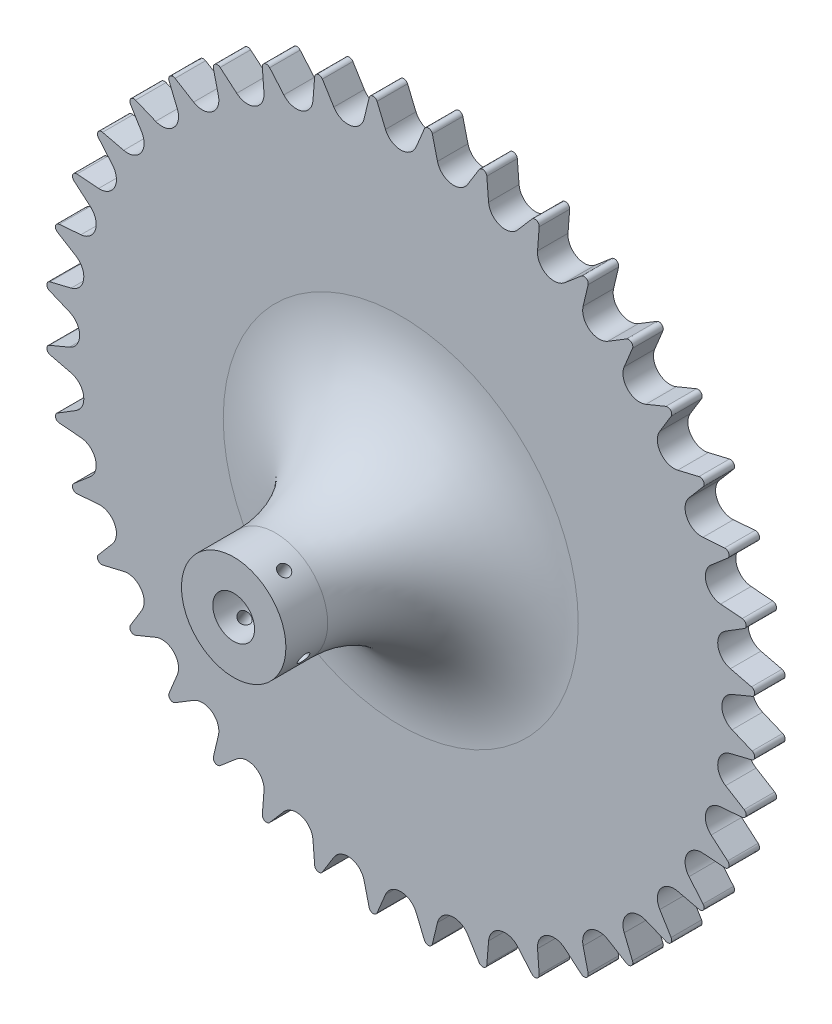
from build123d import *

# Parameters (mm, degrees)
BOSS_EXTRUDE1_DEPTH                 = 7.3
SKETCH2_R                           = 12.5
BOSS_EXTRUDE2_DEPTH                 = 40
FILLET1_R                           = 30
SKETCH3_R                           = 5
CUT_EXTRUDE1_DEPTH                  = 48.3
F_1_0MM_DOWEL_HOLE1_D               = 2.8
F_1_0MM_DOWEL_HOLE1_DEPTH           = 33.158795133
F_1_0MM_DOWEL_HOLE1_TIP             = 0.841204867
F_1_0MM_DOWEL_HOLE1_ON_FACE_2_D     = 2.8
F_1_0MM_DOWEL_HOLE1_ON_FACE_2_DEPTH = 33.158795133
F_1_0MM_DOWEL_HOLE1_ON_FACE_2_TIP   = 0.841204867


with BuildPart() as part:
    # Sketch1 → Boss-Extrude1 (new body)
    with BuildSketch(Plane.XY):
        with BuildLine():
            ThreePointArc((3.662609618, 79.321514688), (0, 76.88125), (-3.662609618, 79.321514688))
            Line((-3.662609618, 79.321514688), (-5.667701775, 84.126186191))
            ThreePointArc((-5.667701775, 84.126186191), (-6.669023137, 84.737973367), (-7.562311971, 83.977077135))
            Line((-7.562311971, 83.977077135), (-8.791101901, 78.917893592))
            ThreePointArc((-8.791101901, 78.917893592), (-12.026877215, 75.934714235), (-16.026135532, 77.77197684))
            Line((-16.026135532, 77.77197684), (-18.758157894, 82.203829344))
            ThreePointArc((-18.758157894, 82.203829344), (-19.842855928, 82.651443234), (-20.606116499, 81.760173735))
            Line((-20.606116499, 81.760173735), (-21.028347314, 76.571052042))
            ThreePointArc((-21.028347314, 76.571052042), (-23.757612799, 73.118413793), (-27.995044802, 74.307434811))
            Line((-27.995044802, 74.307434811), (-31.386725911, 78.2573414))
            ThreePointArc((-31.386725911, 78.2573414), (-32.528091751, 78.529760263), (-33.142530051, 77.530063512))
            Line((-33.142530051, 77.530063512), (-32.747805028, 72.338777067))
            ThreePointArc((-32.747805028, 72.338777067), (-34.903357108, 68.501695338), (-39.274623159, 69.013197125))
            Line((-39.274623159, 69.013197125), (-43.242448569, 72.38389799))
            ThreePointArc((-43.242448569, 72.38389799), (-44.412378001, 72.47441397), (-44.862864519, 71.390905818))
            Line((-44.862864519, 71.390905818), (-43.660903098, 66.325281321))
            ThreePointArc((-43.660903098, 66.325281321), (-45.189664928, 62.198237799), (-49.587129948, 62.019625484))
            Line((-49.587129948, 62.019625484), (-54.03339863, 64.728122783))
            ThreePointArc((-54.03339863, 64.728122783), (-55.203084108, 64.634507076), (-55.478526372, 63.49386709))
            Line((-55.478526372, 63.49386709), (-53.498924832, 58.678637028))
            ThreePointArc((-53.498924832, 58.678637028), (-54.363253221, 54.363253221), (-58.678637028, 53.498924832))
            Line((-58.678637028, 53.498924832), (-63.49386709, 55.478526372))
            ThreePointArc((-63.49386709, 55.478526372), (-64.634507076, 55.203084108), (-64.728122783, 54.03339863))
            Line((-64.728122783, 54.03339863), (-62.019625484, 49.587129948))
            ThreePointArc((-62.019625484, 49.587129948), (-62.198237799, 45.189664928), (-66.325281321, 43.660903098))
            Line((-66.325281321, 43.660903098), (-71.390905818, 44.862864519))
            ThreePointArc((-71.390905818, 44.862864519), (-72.47441397, 44.412378001), (-72.38389799, 43.242448569))
            Line((-72.38389799, 43.242448569), (-69.013197125, 39.274623159))
            ThreePointArc((-69.013197125, 39.274623159), (-68.501695338, 34.903357108), (-72.338777067, 32.747805028))
            Line((-72.338777067, 32.747805028), (-77.530063512, 33.142530051))
            ThreePointArc((-77.530063512, 33.142530051), (-78.529760263, 32.528091751), (-78.2573414, 31.386725911))
            Line((-78.2573414, 31.386725911), (-74.307434811, 27.995044802))
            ThreePointArc((-74.307434811, 27.995044802), (-73.118413793, 23.757612799), (-76.571052042, 21.028347314))
            Line((-76.571052042, 21.028347314), (-81.760173735, 20.606116499))
            ThreePointArc((-81.760173735, 20.606116499), (-82.651443234, 19.842855928), (-82.203829344, 18.758157894))
            Line((-82.203829344, 18.758157894), (-77.77197684, 16.026135532))
            ThreePointArc((-77.77197684, 16.026135532), (-75.934714235, 12.026877215), (-78.917893592, 8.791101901))
            Line((-78.917893592, 8.791101901), (-83.977077135, 7.562311971))
            ThreePointArc((-83.977077135, 7.562311971), (-84.737973367, 6.669023137), (-84.126186191, 5.667701775))
            Line((-84.126186191, 5.667701775), (-79.321514688, 3.662609618))
            ThreePointArc((-79.321514688, 3.662609618), (-76.88125, 0), (-79.321514688, -3.662609618))
            Line((-79.321514688, -3.662609618), (-84.126186191, -5.667701775))
            ThreePointArc((-84.126186191, -5.667701775), (-84.737973367, -6.669023137), (-83.977077135, -7.562311971))
            Line((-83.977077135, -7.562311971), (-78.917893592, -8.791101901))
            ThreePointArc((-78.917893592, -8.791101901), (-75.934714235, -12.026877215), (-77.77197684, -16.026135532))
            Line((-77.77197684, -16.026135532), (-82.203829344, -18.758157894))
            ThreePointArc((-82.203829344, -18.758157894), (-82.651443234, -19.842855928), (-81.760173735, -20.606116499))
            Line((-81.760173735, -20.606116499), (-76.571052042, -21.028347314))
            ThreePointArc((-76.571052042, -21.028347314), (-73.118413793, -23.757612799), (-74.307434811, -27.995044802))
            Line((-74.307434811, -27.995044802), (-78.2573414, -31.386725911))
            ThreePointArc((-78.2573414, -31.386725911), (-78.529760263, -32.528091751), (-77.530063512, -33.142530051))
            Line((-77.530063512, -33.142530051), (-72.338777067, -32.747805028))
            ThreePointArc((-72.338777067, -32.747805028), (-68.501695338, -34.903357108), (-69.013197125, -39.274623159))
            Line((-69.013197125, -39.274623159), (-72.38389799, -43.242448569))
            ThreePointArc((-72.38389799, -43.242448569), (-72.47441397, -44.412378001), (-71.390905818, -44.862864519))
            Line((-71.390905818, -44.862864519), (-66.325281321, -43.660903098))
            ThreePointArc((-66.325281321, -43.660903098), (-62.198237799, -45.189664928), (-62.019625484, -49.587129948))
            Line((-62.019625484, -49.587129948), (-64.728122783, -54.03339863))
            ThreePointArc((-64.728122783, -54.03339863), (-64.634507076, -55.203084108), (-63.49386709, -55.478526372))
            Line((-63.49386709, -55.478526372), (-58.678637028, -53.498924832))
            ThreePointArc((-58.678637028, -53.498924832), (-54.363253221, -54.363253221), (-53.498924832, -58.678637028))
            Line((-53.498924832, -58.678637028), (-55.478526372, -63.49386709))
            ThreePointArc((-55.478526372, -63.49386709), (-55.203084108, -64.634507076), (-54.03339863, -64.728122783))
            Line((-54.03339863, -64.728122783), (-49.587129948, -62.019625484))
            ThreePointArc((-49.587129948, -62.019625484), (-45.189664928, -62.198237799), (-43.660903098, -66.325281321))
            Line((-43.660903098, -66.325281321), (-44.862864519, -71.390905818))
            ThreePointArc((-44.862864519, -71.390905818), (-44.412378001, -72.47441397), (-43.242448569, -72.38389799))
            Line((-43.242448569, -72.38389799), (-39.274623159, -69.013197125))
            ThreePointArc((-39.274623159, -69.013197125), (-34.903357108, -68.501695338), (-32.747805028, -72.338777067))
            Line((-32.747805028, -72.338777067), (-33.142530051, -77.530063512))
            ThreePointArc((-33.142530051, -77.530063512), (-32.528091751, -78.529760263), (-31.386725911, -78.2573414))
            Line((-31.386725911, -78.2573414), (-27.995044802, -74.307434811))
            ThreePointArc((-27.995044802, -74.307434811), (-23.757612799, -73.118413793), (-21.028347314, -76.571052042))
            Line((-21.028347314, -76.571052042), (-20.606116499, -81.760173735))
            ThreePointArc((-20.606116499, -81.760173735), (-19.842855928, -82.651443234), (-18.758157894, -82.203829344))
            Line((-18.758157894, -82.203829344), (-16.026135532, -77.77197684))
            ThreePointArc((-16.026135532, -77.77197684), (-12.026877215, -75.934714235), (-8.791101901, -78.917893592))
            Line((-8.791101901, -78.917893592), (-7.562311971, -83.977077135))
            ThreePointArc((-7.562311971, -83.977077135), (-6.669023137, -84.737973367), (-5.667701775, -84.126186191))
            Line((-5.667701775, -84.126186191), (-3.662609618, -79.321514688))
            ThreePointArc((-3.662609618, -79.321514688), (0, -76.88125), (3.662609618, -79.321514688))
            Line((3.662609618, -79.321514688), (5.667701775, -84.126186191))
            ThreePointArc((5.667701775, -84.126186191), (6.669023137, -84.737973367), (7.562311971, -83.977077135))
            Line((7.562311971, -83.977077135), (8.791101901, -78.917893592))
            ThreePointArc((8.791101901, -78.917893592), (12.026877215, -75.934714235), (16.026135532, -77.77197684))
            Line((16.026135532, -77.77197684), (18.758157894, -82.203829344))
            ThreePointArc((18.758157894, -82.203829344), (19.842855928, -82.651443234), (20.606116499, -81.760173735))
            Line((20.606116499, -81.760173735), (21.028347314, -76.571052042))
            ThreePointArc((21.028347314, -76.571052042), (23.757612799, -73.118413793), (27.995044802, -74.307434811))
            Line((27.995044802, -74.307434811), (31.386725911, -78.2573414))
            ThreePointArc((31.386725911, -78.2573414), (32.528091751, -78.529760263), (33.142530051, -77.530063512))
            Line((33.142530051, -77.530063512), (32.747805028, -72.338777067))
            ThreePointArc((32.747805028, -72.338777067), (34.903357108, -68.501695338), (39.274623159, -69.013197125))
            Line((39.274623159, -69.013197125), (43.242448569, -72.38389799))
            ThreePointArc((43.242448569, -72.38389799), (44.412378001, -72.47441397), (44.862864519, -71.390905818))
            Line((44.862864519, -71.390905818), (43.660903098, -66.325281321))
            ThreePointArc((43.660903098, -66.325281321), (45.189664928, -62.198237799), (49.587129948, -62.019625484))
            Line((49.587129948, -62.019625484), (54.03339863, -64.728122783))
            ThreePointArc((54.03339863, -64.728122783), (55.203084108, -64.634507076), (55.478526372, -63.49386709))
            Line((55.478526372, -63.49386709), (53.498924832, -58.678637028))
            ThreePointArc((53.498924832, -58.678637028), (54.363253221, -54.363253221), (58.678637028, -53.498924832))
            Line((58.678637028, -53.498924832), (63.49386709, -55.478526372))
            ThreePointArc((63.49386709, -55.478526372), (64.634507076, -55.203084108), (64.728122783, -54.03339863))
            Line((64.728122783, -54.03339863), (62.019625484, -49.587129948))
            ThreePointArc((62.019625484, -49.587129948), (62.198237799, -45.189664928), (66.325281321, -43.660903098))
            Line((66.325281321, -43.660903098), (71.390905818, -44.862864519))
            ThreePointArc((71.390905818, -44.862864519), (72.47441397, -44.412378001), (72.38389799, -43.242448569))
            Line((72.38389799, -43.242448569), (69.013197125, -39.274623159))
            ThreePointArc((69.013197125, -39.274623159), (68.501695338, -34.903357108), (72.338777067, -32.747805028))
            Line((72.338777067, -32.747805028), (77.530063512, -33.142530051))
            ThreePointArc((77.530063512, -33.142530051), (78.529760263, -32.528091751), (78.2573414, -31.386725911))
            Line((78.2573414, -31.386725911), (74.307434811, -27.995044802))
            ThreePointArc((74.307434811, -27.995044802), (73.118413793, -23.757612799), (76.571052042, -21.028347314))
            Line((76.571052042, -21.028347314), (81.760173735, -20.606116499))
            ThreePointArc((81.760173735, -20.606116499), (82.651443234, -19.842855928), (82.203829344, -18.758157894))
            Line((82.203829344, -18.758157894), (77.77197684, -16.026135532))
            ThreePointArc((77.77197684, -16.026135532), (75.934714235, -12.026877215), (78.917893592, -8.791101901))
            Line((78.917893592, -8.791101901), (83.977077135, -7.562311971))
            ThreePointArc((83.977077135, -7.562311971), (84.737973367, -6.669023137), (84.126186191, -5.667701775))
            Line((84.126186191, -5.667701775), (79.321514688, -3.662609618))
            ThreePointArc((79.321514688, -3.662609618), (76.88125, 0), (79.321514688, 3.662609618))
            Line((79.321514688, 3.662609618), (84.126186191, 5.667701775))
            ThreePointArc((84.126186191, 5.667701775), (84.737973367, 6.669023137), (83.977077135, 7.562311971))
            Line((83.977077135, 7.562311971), (78.917893592, 8.791101901))
            ThreePointArc((78.917893592, 8.791101901), (75.934714235, 12.026877215), (77.77197684, 16.026135532))
            Line((77.77197684, 16.026135532), (82.203829344, 18.758157894))
            ThreePointArc((82.203829344, 18.758157894), (82.651443234, 19.842855928), (81.760173735, 20.606116499))
            Line((81.760173735, 20.606116499), (76.571052042, 21.028347314))
            ThreePointArc((76.571052042, 21.028347314), (73.118413793, 23.757612799), (74.307434811, 27.995044802))
            Line((74.307434811, 27.995044802), (78.2573414, 31.386725911))
            ThreePointArc((78.2573414, 31.386725911), (78.529760263, 32.528091751), (77.530063512, 33.142530051))
            Line((77.530063512, 33.142530051), (72.338777067, 32.747805028))
            ThreePointArc((72.338777067, 32.747805028), (68.501695338, 34.903357108), (69.013197125, 39.274623159))
            Line((69.013197125, 39.274623159), (72.38389799, 43.242448569))
            ThreePointArc((72.38389799, 43.242448569), (72.47441397, 44.412378001), (71.390905818, 44.862864519))
            Line((71.390905818, 44.862864519), (66.325281321, 43.660903098))
            ThreePointArc((66.325281321, 43.660903098), (62.198237799, 45.189664928), (62.019625484, 49.587129948))
            Line((62.019625484, 49.587129948), (64.728122783, 54.03339863))
            ThreePointArc((64.728122783, 54.03339863), (64.634507076, 55.203084108), (63.49386709, 55.478526372))
            Line((63.49386709, 55.478526372), (58.678637028, 53.498924832))
            ThreePointArc((58.678637028, 53.498924832), (54.363253221, 54.363253221), (53.498924832, 58.678637028))
            Line((53.498924832, 58.678637028), (55.478526372, 63.49386709))
            ThreePointArc((55.478526372, 63.49386709), (55.203084108, 64.634507076), (54.03339863, 64.728122783))
            Line((54.03339863, 64.728122783), (49.587129948, 62.019625484))
            ThreePointArc((49.587129948, 62.019625484), (45.189664928, 62.198237799), (43.660903098, 66.325281321))
            Line((43.660903098, 66.325281321), (44.862864519, 71.390905818))
            ThreePointArc((44.862864519, 71.390905818), (44.412378001, 72.47441397), (43.242448569, 72.38389799))
            Line((43.242448569, 72.38389799), (39.274623159, 69.013197125))
            ThreePointArc((39.274623159, 69.013197125), (34.903357108, 68.501695338), (32.747805028, 72.338777067))
            Line((32.747805028, 72.338777067), (33.142530051, 77.530063512))
            ThreePointArc((33.142530051, 77.530063512), (32.528091751, 78.529760263), (31.386725911, 78.2573414))
            Line((31.386725911, 78.2573414), (27.995044802, 74.307434811))
            ThreePointArc((27.995044802, 74.307434811), (23.757612799, 73.118413793), (21.028347314, 76.571052042))
            Line((21.028347314, 76.571052042), (20.606116499, 81.760173735))
            ThreePointArc((20.606116499, 81.760173735), (19.842855928, 82.651443234), (18.758157894, 82.203829344))
            Line((18.758157894, 82.203829344), (16.026135532, 77.77197684))
            ThreePointArc((16.026135532, 77.77197684), (12.026877215, 75.934714235), (8.791101901, 78.917893592))
            Line((8.791101901, 78.917893592), (7.562311971, 83.977077135))
            ThreePointArc((7.562311971, 83.977077135), (6.669023137, 84.737973367), (5.667701775, 84.126186191))
            Line((5.667701775, 84.126186191), (3.662609618, 79.321514688))
        make_face()
    extrude(amount=BOSS_EXTRUDE1_DEPTH)

    # Sketch2 → Boss-Extrude2 (add)
    with BuildSketch(Plane.XY.offset(7.3)):
        Circle(SKETCH2_R)
    extrude(amount=BOSS_EXTRUDE2_DEPTH)

    # Fillet1
    fillet1_edges = [part.edges().sort_by_distance(p)[0] for p in [
        (-12.5, 0, 7.3),
    ]]
    fillet(fillet1_edges, radius=FILLET1_R)

    # Sketch3 → Cut-Extrude1 (cut, through all)
    with BuildSketch(Plane.XY.offset(47.3)):
        Circle(SKETCH3_R)
    extrude(amount=-CUT_EXTRUDE1_DEPTH, mode=Mode.SUBTRACT)

    # Ø1.0mm Dowel Hole1
    with Locations(Plane(origin=(-6.81763654, -10.477109907, 42.020116055), x_dir=(-0.838168793, 0.545410923, 0), z_dir=(-0.545410923, -0.838168793, 0))):
        with Locations((0, 0)):
            Hole(F_1_0MM_DOWEL_HOLE1_D / 2, depth=F_1_0MM_DOWEL_HOLE1_DEPTH)
            with Locations((0, 0, -(F_1_0MM_DOWEL_HOLE1_DEPTH + F_1_0MM_DOWEL_HOLE1_TIP / 2))):  # 118° drill point
                Cone(0, F_1_0MM_DOWEL_HOLE1_D / 2, F_1_0MM_DOWEL_HOLE1_TIP, mode=Mode.SUBTRACT)

    # Ø1.0mm Dowel Hole1 on face 2
    with Locations(Plane(origin=(-11.068439798, 5.808583342, 41.658255729), x_dir=(-0.464687004, -0.885475007, 0), z_dir=(-0.885475007, 0.464687004, 0))):
        with Locations((0, 0)):
            Hole(F_1_0MM_DOWEL_HOLE1_ON_FACE_2_D / 2, depth=F_1_0MM_DOWEL_HOLE1_ON_FACE_2_DEPTH)
            with Locations((0, 0, -(F_1_0MM_DOWEL_HOLE1_ON_FACE_2_DEPTH + F_1_0MM_DOWEL_HOLE1_ON_FACE_2_TIP / 2))):  # 118° drill point
                Cone(0, F_1_0MM_DOWEL_HOLE1_ON_FACE_2_D / 2, F_1_0MM_DOWEL_HOLE1_ON_FACE_2_TIP, mode=Mode.SUBTRACT)


solid = part.part
